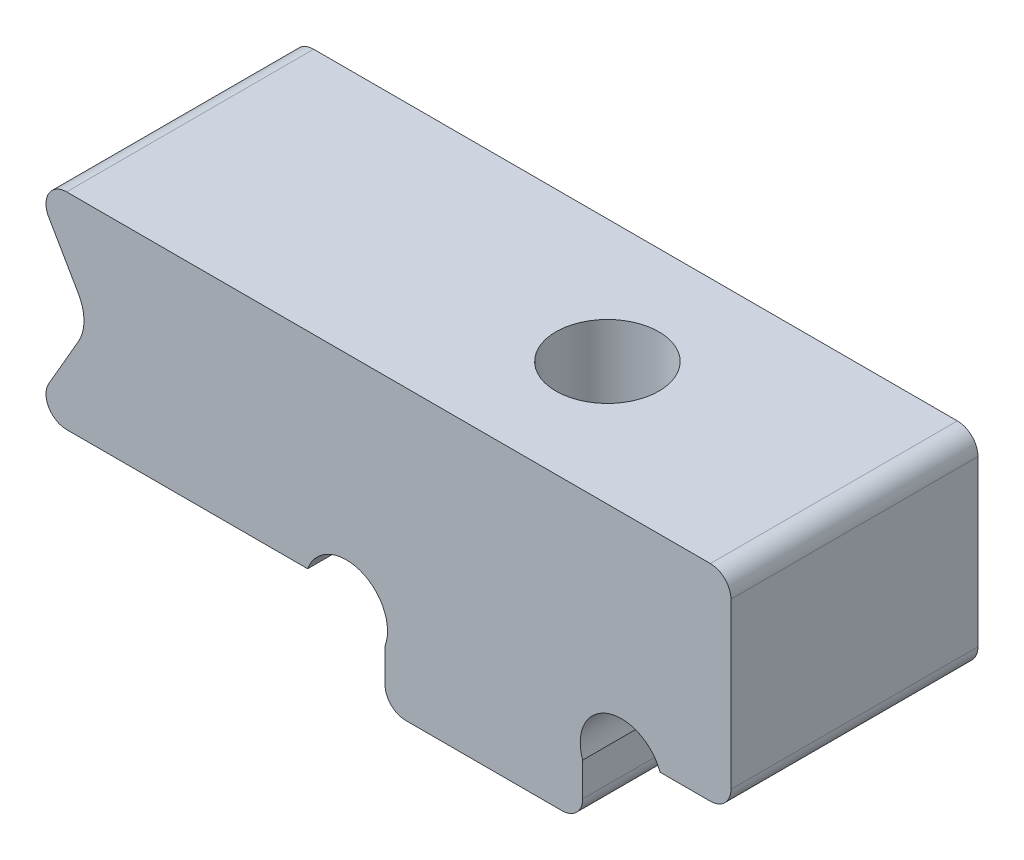
from build123d import *

# Parameters (mm, degrees)
BOSS_EXTRU_1_DEPTH      = 3
ESQUISSE2_R             = 1.25
ENL_V_MAT_EXTRU_1_DEPTH = 8
ESQUISSE3_W             = 6
ESQUISSE3_H             = 5
BOSS_EXTRU_2_DEPTH      = 5
ENL_V_MAT_EXTRU_3_DEPTH = 7
CONG_4_R                = 0.5
CONG_5_R                = 1
ENL_V_MAT_EXTRU_5_DEPTH = 7


with BuildPart() as part:
    # Esquisse1 → Boss.-Extru.1 (new body, symmetric)
    with BuildSketch(Plane.XY):
        Polygon((-6, 0), (-2.4, 0), (-2.4, -2), (2.4, -2), (2.4, 0), (6, 0), (6, 5), (-6, 5), align=None)
    extrude(amount=BOSS_EXTRU_1_DEPTH, both=True)

    # Esquisse2 → Enlèv. mat.-Extru.1 (cut, through all)
    with BuildSketch(Plane(origin=(0, 5, 0), x_dir=(1, 0, 0), z_dir=(0, 1, 0))):
        Circle(ESQUISSE2_R)
    extrude(amount=-ENL_V_MAT_EXTRU_1_DEPTH, mode=Mode.SUBTRACT)

    # Esquisse3 → Boss.-Extru.2 (add)
    with BuildSketch(Plane.ZY.offset(6)):
        with Locations((0, 2.5)):
            Rectangle(ESQUISSE3_W, ESQUISSE3_H)
    extrude(amount=BOSS_EXTRU_2_DEPTH)

    # Esquisse7 → Enlèv. mat.-Extru.3 (cut, through all)
    with BuildSketch(Plane.XY.offset(3)):
        Polygon((-11, 5), (-9.556624327, 2.5), (-11, 0), align=None)
    extrude(amount=-ENL_V_MAT_EXTRU_3_DEPTH, mode=Mode.SUBTRACT)

    # Congé4
    cong_4_edges = [part.edges().sort_by_distance(p)[0] for p in [
        (6, 0, 0),
        (2.4, -2, 0),
        (-2.4, -2, 0),
        (6, 5, 0),
        (-11, 0, 0),
        (-11, 5, 0),
    ]]
    fillet(cong_4_edges, radius=CONG_4_R)

    # Congé5
    cong_5_edges = [part.edges().sort_by_distance(p)[0] for p in [
        (-9.556624327, 2.5, 0),
    ]]
    fillet(cong_5_edges, radius=CONG_5_R)

    # Esquisse12 → Enlèv. mat.-Extru.5 (cut, through all)
    with BuildSketch(Plane(origin=(0, 0, -3), x_dir=(-1, 0, 0), z_dir=(0, 0, -1))):
        with BuildLine():
            Line((-4.279385242, 0), (-2.4, -0.684040287))
            ThreePointArc((-2.4, -0.684040287), (-2.997672477, 0.597672477), (-4.279385242, 0))
        make_face()
        with BuildLine():
            Line((4.279385242, 0), (2.4, -0.684040287))
            ThreePointArc((2.4, -0.684040287), (2.997672477, 0.597672477), (4.279385242, 0))
        make_face()
    extrude(amount=-ENL_V_MAT_EXTRU_5_DEPTH, mode=Mode.SUBTRACT)


solid = part.part
